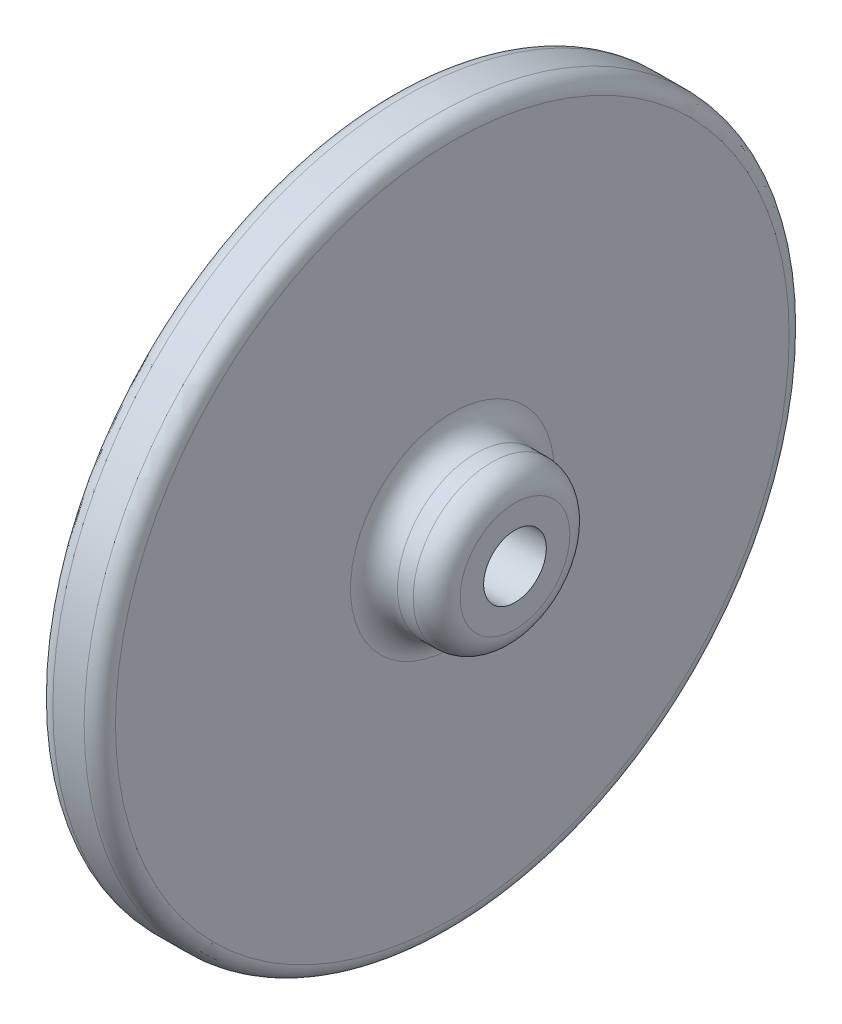
from build123d import *

# Parameters (mm, degrees)
SPROCKET_R                    = 45
ESTRUSIONE_ESTRUSIONE2_DEPTH  = 8
SCHIZZO4_R                    = 10
ESTRUSIONE_ESTRUSIONE4_DEPTH  = 8
RACCORDO1_R                   = 2
RACCORDO2_R                   = 3
ESTRUSIONE_ESTRUSIONE5_START  = 8
SCHIZZO7_R                    = 10
ESTRUSIONE_ESTRUSIONE5_DEPTH  = 8
RACCORDO3_R                   = 3
TAGLIO_ESTRUSIONE4_DEPTH      = 66.620119003
TAGLIO_ESTRUSIONE4_DEPTH_BACK = 66.620119003
SCHIZZO6_R                    = 4


with BuildPart() as part:
    # Sprocket → Estrusione-Estrusione2 (new body)
    with BuildSketch(Plane(origin=(0, 0, 0), x_dir=(0, 0, -1), z_dir=(1, 0, 0))):
        Circle(SPROCKET_R)
    extrude(amount=ESTRUSIONE_ESTRUSIONE2_DEPTH)

    # Schizzo4 → Estrusione-Estrusione4 (add)
    with BuildSketch(Plane(origin=(8, 0, 0), x_dir=(0, 0, -1), z_dir=(1, 0, 0))):
        Circle(SCHIZZO4_R)
    extrude(amount=ESTRUSIONE_ESTRUSIONE4_DEPTH)

    # Raccordo1
    raccordo1_edges = [part.edges().sort_by_distance(p)[0] for p in [
        (8, 0, 45),
        (0, 0, 45),
    ]]
    fillet(raccordo1_edges, radius=RACCORDO1_R)

    # Raccordo2
    raccordo2_edges = [part.edges().sort_by_distance(p)[0] for p in [
        (8, 0, 10),
        (16, 0, 10),
    ]]
    fillet(raccordo2_edges, radius=RACCORDO2_R)

    # Schizzo7 → Estrusione-Estrusione5 (add)
    with BuildSketch(Plane.ZY.offset(ESTRUSIONE_ESTRUSIONE5_START)):
        Circle(SCHIZZO7_R)
    extrude(amount=-ESTRUSIONE_ESTRUSIONE5_DEPTH)

    # Raccordo3
    raccordo3_edges = [part.edges().sort_by_distance(p)[0] for p in [
        (0, 0, -10),
        (-8, 0, -10),
    ]]
    fillet(raccordo3_edges, radius=RACCORDO3_R)

    # Schizzo6 → Taglio-Estrusione4 (cut, two sides: drawn at the far end of the back side and taken through both)
    with BuildSketch(Plane(origin=(0, 0, 0), x_dir=(0, 0, -1), z_dir=(1, 0, 0)).offset(-TAGLIO_ESTRUSIONE4_DEPTH_BACK)):
        Circle(SCHIZZO6_R)
    extrude(amount=TAGLIO_ESTRUSIONE4_DEPTH + TAGLIO_ESTRUSIONE4_DEPTH_BACK, mode=Mode.SUBTRACT)


solid = part.part
